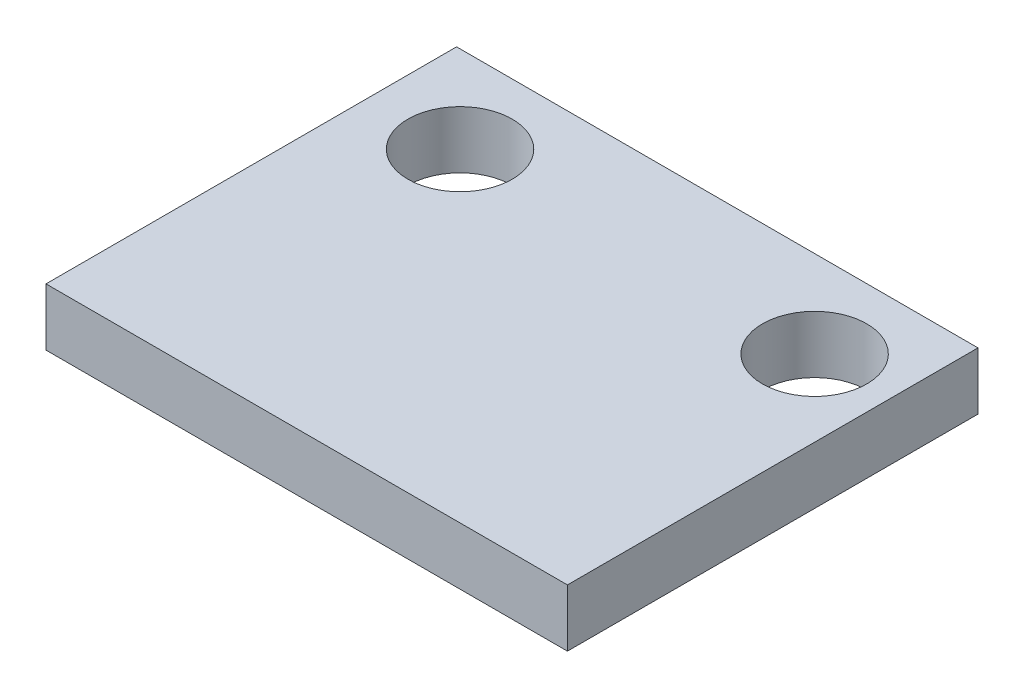
from build123d import *

# Parameters (mm, degrees)
SKETCH1_W           = 15
SKETCH1_H           = 11.811
SKETCH1_R           = 1.5
BOSS_EXTRUDE1_DEPTH = 1.651


with BuildPart() as part:
    # Sketch1 → Boss-Extrude1 (new body)
    with BuildSketch(Plane(origin=(0, 0, 0), x_dir=(1, 0, 0), z_dir=(0, 1, 0))):
        with Locations((7.5, 5.9055)):
            Rectangle(SKETCH1_W, SKETCH1_H)
        with Locations((2.6, 9.311)):
            Circle(SKETCH1_R, mode=Mode.SUBTRACT)
        with Locations((12.8, 9.311)):
            Circle(SKETCH1_R, mode=Mode.SUBTRACT)
    extrude(amount=BOSS_EXTRUDE1_DEPTH)


solid = part.part
